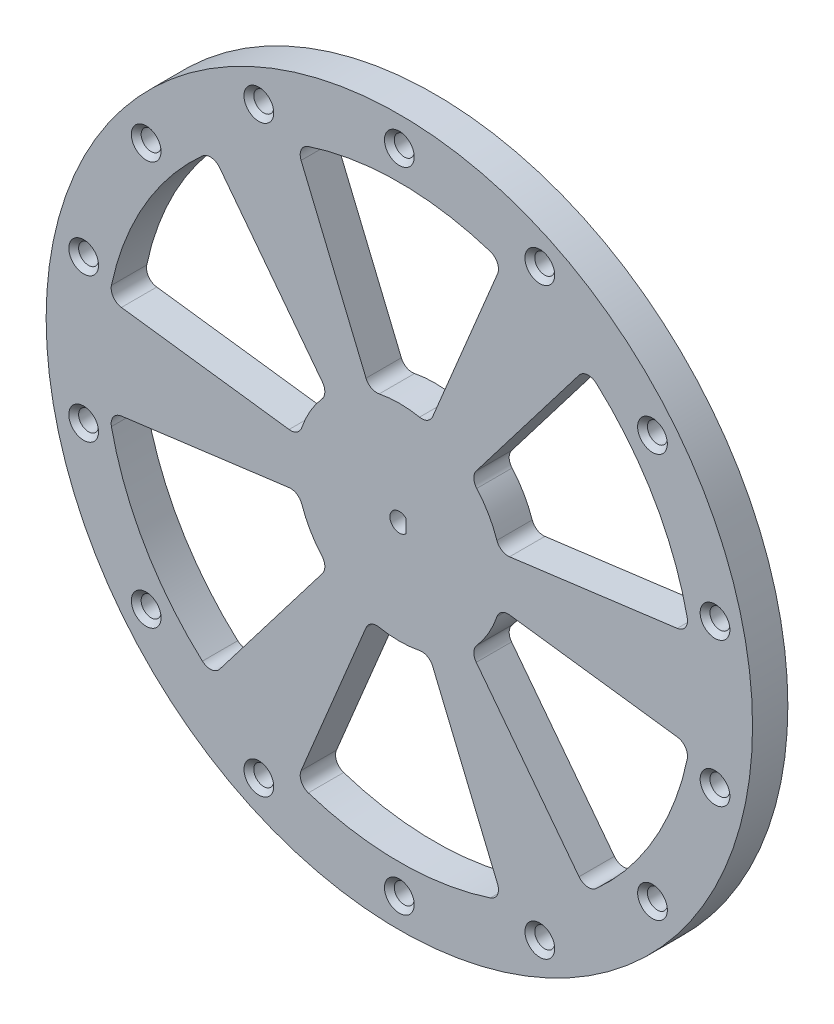
from build123d import *

# Parameters (mm, degrees)
SKETCH1_R               = 60
SKETCH1_R_2             = 17.5
BOSS_EXTRUDE2_DEPTH     = 3
FILLET1_R               = 2
CUT_EXTRUDE1_DEPTH      = 86.064681273
CUT_EXTRUDE1_DEPTH_BACK = 86.064681273
CIRPATTERN4_COUNT       = 14


with BuildPart() as part:
    # Sketch1 → Boss-Extrude2 (new, symmetric)
    with BuildSketch(Plane.XY):
        Circle(SKETCH1_R)
        with BuildLine():
            ThreePointArc((-12.023687548, 12.715381935), (-8.75, 15.155444566), (-5, 16.770509831))
            Line((-5, 16.770509831), (-17.5, 46.837484988))
            ThreePointArc((-17.5, 46.837484988), (0, 50), (17.5, 46.837484988))
            Line((17.5, 46.837484988), (5, 16.770509831))
            ThreePointArc((5, 16.770509831), (8.75, 15.155444566), (12.023687548, 12.715381935))
            Line((12.023687548, 12.715381935), (31.812451849, 38.57418706))
            ThreePointArc((31.812451849, 38.57418706), (43.301270189, 25), (49.312451849, 8.263297928))
            Line((49.312451849, 8.263297928), (17.023687548, 4.055127897))
            ThreePointArc((17.023687548, 4.055127897), (17.380513975, 2.041502866), (17.5, 0))
            ThreePointArc((17.5, 0), (17.380513975, -2.041502866), (17.023687548, -4.055127897))
            Line((17.023687548, -4.055127897), (49.312451849, -8.263297928))
            ThreePointArc((49.312451849, -8.263297928), (43.301270189, -25), (31.812451849, -38.57418706))
            Line((31.812451849, -38.57418706), (12.023687548, -12.715381935))
            ThreePointArc((12.023687548, -12.715381935), (8.75, -15.155444566), (5, -16.770509831))
            Line((5, -16.770509831), (17.5, -46.837484988))
            ThreePointArc((17.5, -46.837484988), (0, -50), (-17.5, -46.837484988))
            Line((-17.5, -46.837484988), (-5, -16.770509831))
            ThreePointArc((-5, -16.770509831), (-8.75, -15.155444566), (-12.023687548, -12.715381935))
            Line((-12.023687548, -12.715381935), (-31.812451849, -38.57418706))
            ThreePointArc((-31.812451849, -38.57418706), (-43.301270189, -25), (-49.312451849, -8.263297928))
            Line((-49.312451849, -8.263297928), (-17.023687548, -4.055127897))
            ThreePointArc((-17.023687548, -4.055127897), (-17.5, 0), (-17.023687548, 4.055127897))
            Line((-17.023687548, 4.055127897), (-49.312451849, 8.263297928))
            ThreePointArc((-49.312451849, 8.263297928), (-43.301270189, 25), (-31.812451849, 38.57418706))
            Line((-31.812451849, 38.57418706), (-12.023687548, 12.715381935))
        make_face(mode=Mode.SUBTRACT)
        Circle(SKETCH1_R_2)
    extrude(amount=BOSS_EXTRUDE2_DEPTH, both=True)

    # Fillet1
    fillet1_edges = [part.edges().sort_by_distance(p)[0] for p in [
        (12.023687548, -12.715381935, 0),
        (31.812451849, -38.57418706, 0),
        (49.312451849, -8.263297928, 0),
        (17.023687548, -4.055127897, 0),
        (-17.5, -46.837484988, 0),
        (17.5, -46.837484988, 0),
        (5, -16.770509831, 0),
        (-5, -16.770509831, 0),
        (-49.312451849, -8.263297928, 0),
        (-31.812451849, -38.57418706, 0),
        (-12.023687548, -12.715381935, 0),
        (-17.023687548, -4.055127897, 0),
        (-31.812451849, 38.57418706, 0),
        (-49.312451849, 8.263297928, 0),
        (-17.023687548, 4.055127897, 0),
        (-12.023687548, 12.715381935, 0),
        (17.5, 46.837484988, 0),
        (-17.5, 46.837484988, 0),
        (-5, 16.770509831, 0),
        (5, 16.770509831, 0),
        (49.312451849, 8.263297928, 0),
        (31.812451849, 38.57418706, 0),
        (12.023687548, 12.715381935, 0),
        (17.023687548, 4.055127897, 0),
    ]]
    fillet(fillet1_edges, radius=FILLET1_R)

    # Sketch4 → Cut-Extrude1 (cut, two sides)
    with BuildSketch(Plane(origin=(0, 0, -3), x_dir=(-1, 0, 0), z_dir=(0, 0, -1))) as cut_extrude1_sk:
        with BuildLine():
            Line((-1.1, 1.161895004), (-1.1, -1.161895004))
            ThreePointArc((-1.1, -1.161895004), (1.6, 0), (-1.1, 1.161895004))
        make_face()
    extrude(amount=CUT_EXTRUDE1_DEPTH, mode=Mode.SUBTRACT)
    extrude(cut_extrude1_sk.sketch, amount=-CUT_EXTRUDE1_DEPTH_BACK, mode=Mode.SUBTRACT)

    # Sketch6 → Ø5.0mm Dowel Hole1 (revolve, cut)
    with BuildSketch(Plane(origin=(0, 55, 3), x_dir=(0, -1, 0), z_dir=(1, 0, 0))):
        Polygon((0, 0), (0, 21.016639932), (1.69197298, 20), (1.69197298, 0.83302702), (2.525, 0), align=None)
    f_5_0mm_dowel_hole1 = revolve(axis=Axis((0, 55, 9.35), (0, 0, -1)), mode=Mode.SUBTRACT)

    # CirPattern4: Ø5.0mm Dowel Hole1 ×14 about axis
    cirpattern4_axis = Axis((0, 0, 0), (0, 0, 1))
    for i in range(1, CIRPATTERN4_COUNT):
        add(f_5_0mm_dowel_hole1.rotate(cirpattern4_axis, i * 360 / CIRPATTERN4_COUNT), mode=Mode.SUBTRACT)


solid = part.part
